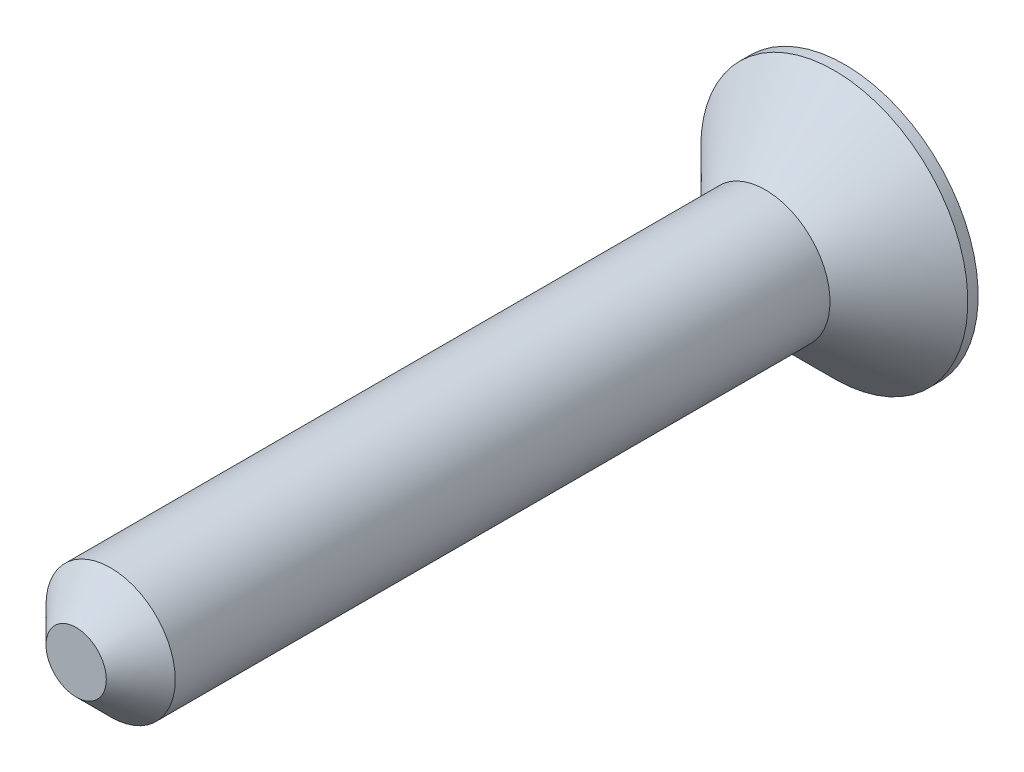
from build123d import *

# Parameters (mm, degrees)
SKETCH1_R           = 4.7625
BASE_EXTRUDE_DEPTH  = 50.8
SKETCH2_R           = 4.7625
BOSS_EXTRUDE1_DEPTH = 5.08
BOSS_EXTRUDE1_TAPER = -45
SKETCH3_W           = 1.754126852
SKETCH3_H           = 4.225851054
CUT_EXTRUDE1_DEPTH  = 3.175
CIRPATTERN1_COUNT   = 4
SKETCH4_R           = 9.8425
BOSS_EXTRUDE2_DEPTH = 0.762
CHAMFER1_SIZE       = 2.54


with BuildPart() as part:
    # Sketch1 → Base-Extrude (new body)
    with BuildSketch(Plane.XY):
        Circle(SKETCH1_R)
    extrude(amount=BASE_EXTRUDE_DEPTH)

    # Sketch2 → Boss-Extrude1 (add)
    with BuildSketch(Plane(origin=(0, 0, 0), x_dir=(-1, 0, 0), z_dir=(0, 0, -1))):
        Circle(SKETCH2_R)
    extrude(amount=BOSS_EXTRUDE1_DEPTH, taper=BOSS_EXTRUDE1_TAPER)

    # Sketch3 → Cut-Extrude1 (cut)
    with BuildSketch(Plane(origin=(0, 0, -5.08), x_dir=(-1, 0, 0), z_dir=(0, 0, -1))):
        with Locations((0, 2.112925527)):
            Rectangle(SKETCH3_W, SKETCH3_H)
    cut_extrude1 = extrude(amount=-CUT_EXTRUDE1_DEPTH, mode=Mode.SUBTRACT)

    # CirPattern1: Cut-Extrude1 ×4 about axis
    cirpattern1_axis = Axis((0, 0, 0), (0, 0, -1))
    for i in range(1, CIRPATTERN1_COUNT):
        add(cut_extrude1.rotate(cirpattern1_axis, i * 360 / CIRPATTERN1_COUNT), mode=Mode.SUBTRACT)

    # Sketch4 → Boss-Extrude2 (add)
    with BuildSketch(Plane(origin=(0, 0, -5.08), x_dir=(-1, 0, 0), z_dir=(0, 0, -1))):
        Circle(SKETCH4_R)
        Polygon((-0.877063426, 0.877063426), (-4.225851054, 0.877063426), (-4.225851054, -0.877063426), (-0.877063426, -0.877063426), (-0.877063426, -4.225851054), (0.877063426, -4.225851054), (0.877063426, -0.877063426), (4.225851054, -0.877063426), (4.225851054, 0.877063426), (0.877063426, 0.877063426), (0.877063426, 4.225851054), (-0.877063426, 4.225851054), align=None, mode=Mode.SUBTRACT)
    extrude(amount=BOSS_EXTRUDE2_DEPTH)

    # Chamfer1
    chamfer1_edges = [part.edges().sort_by_distance(p)[0] for p in [
        (-4.7625, 0, 50.8),
    ]]
    chamfer(chamfer1_edges, length=CHAMFER1_SIZE)


solid = part.part
